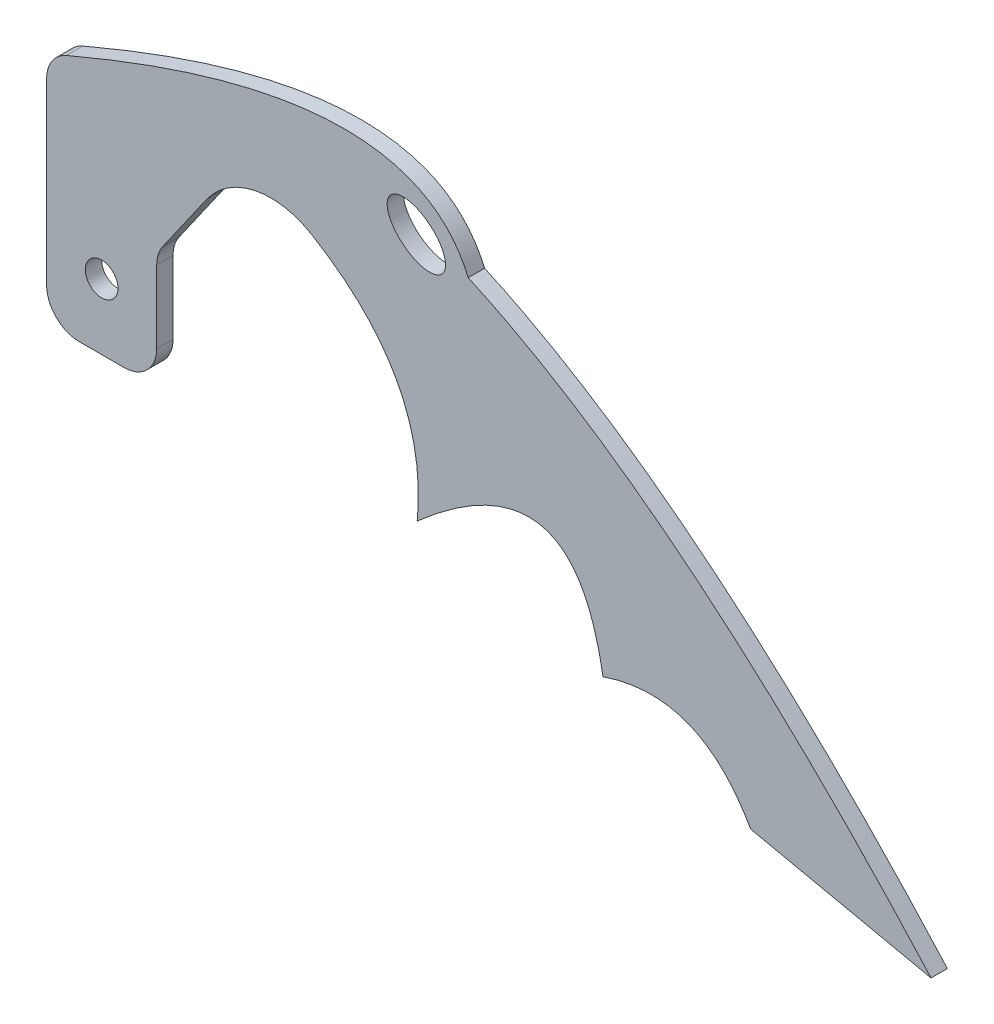
from build123d import *

# Parameters (mm, degrees)
SKETCH1_R           = 3.175
SKETCH1_RX          = 6.501731069
SKETCH1_RY          = 3.917709747
BOSS_EXTRUDE1_DEPTH = 3.175
FILLET1_R           = 6.35
FILLET2_R           = 15.24
FILLET3_R           = 6.35


with BuildPart() as part:
    # Sketch1 → Boss-Extrude1 (new body)
    with BuildSketch(Plane.XY):
        with BuildLine():
            Line((85.837990546, -35.686780557), (50.815428811, -28.169433219))
            add(Edge.make_bspline(
                [(22.151507794, -16.88306006), (40.93348508, -10.477937426), (50.815428811, -28.169433219)],
                knots=[0, 0, 0, 1, 1, 1], degree=2))
            add(Edge.make_bspline(
                [(-13.89812039, -8.73455109), (16.354395889, 17.832088288), (22.151507794, -16.88306006)],
                knots=[0, 0, 0, 1, 1, 1], degree=2))
            add(Edge.make_bspline(
                [(-47.440785313, 35.367440163), (-10.94231892, 21.565916132), (-13.89812039, -8.73455109)],
                knots=[0, 0, 0, 1, 1, 1], degree=2))
            Line((-47.440785313, 35.367440163), (-64.461456133, 11.041010118))
            Line((-64.461456133, 11.041010118), (-64.461456133, -11.388692522))
            Line((-64.461456133, -11.388692522), (-85.837990546, -11.388692522))
            Line((-85.837990546, -11.388692522), (-85.837990546, 33.806971222))
            add(Edge.make_bspline(
                [(-85.837990546, 33.806971222), (-15.708828484, 64.705105309), (-3.996524698, 37.11343766)],
                knots=[0, 0, 0, 0.406769717, 0.406769717, 0.406769717], degree=2))
            add(Edge.make_bspline(
                [(85.837990546, -35.686780557), (37.045439563, 18.631346841), (-3.996524698, 37.11343766)],
                knots=[0, 0, 0, 0.371923551, 0.371923551, 0.371923551], degree=2))
        make_face()
        with Locations((-75.14972334, 1.323731685)):
            Circle(SKETCH1_R, mode=Mode.SUBTRACT)
        with Locations(Location((-14.065908589, 39.346528079), (0, 0, 142.125016349))):
            Ellipse(SKETCH1_RX, SKETCH1_RY, mode=Mode.SUBTRACT)
    extrude(amount=BOSS_EXTRUDE1_DEPTH)

    # Fillet1
    fillet1_edges = [part.edges().sort_by_distance(p)[0] for p in [
        (-64.461456133, 11.041010118, 1.5875),
        (-64.461456133, -11.388692522, 1.5875),
        (-85.837990546, -11.388692522, 1.5875),
    ]]
    fillet(fillet1_edges, radius=FILLET1_R)

    # Fillet2
    fillet2_edges = [part.edges().sort_by_distance(p)[0] for p in [
        (-47.440785313, 35.367440163, 1.5875),
    ]]
    fillet(fillet2_edges, radius=FILLET2_R)

    # Fillet3
    fillet3_edges = [part.edges().sort_by_distance(p)[0] for p in [
        (-85.837990546, 33.806971222, 1.5875),
    ]]
    fillet(fillet3_edges, radius=FILLET3_R)


solid = part.part
